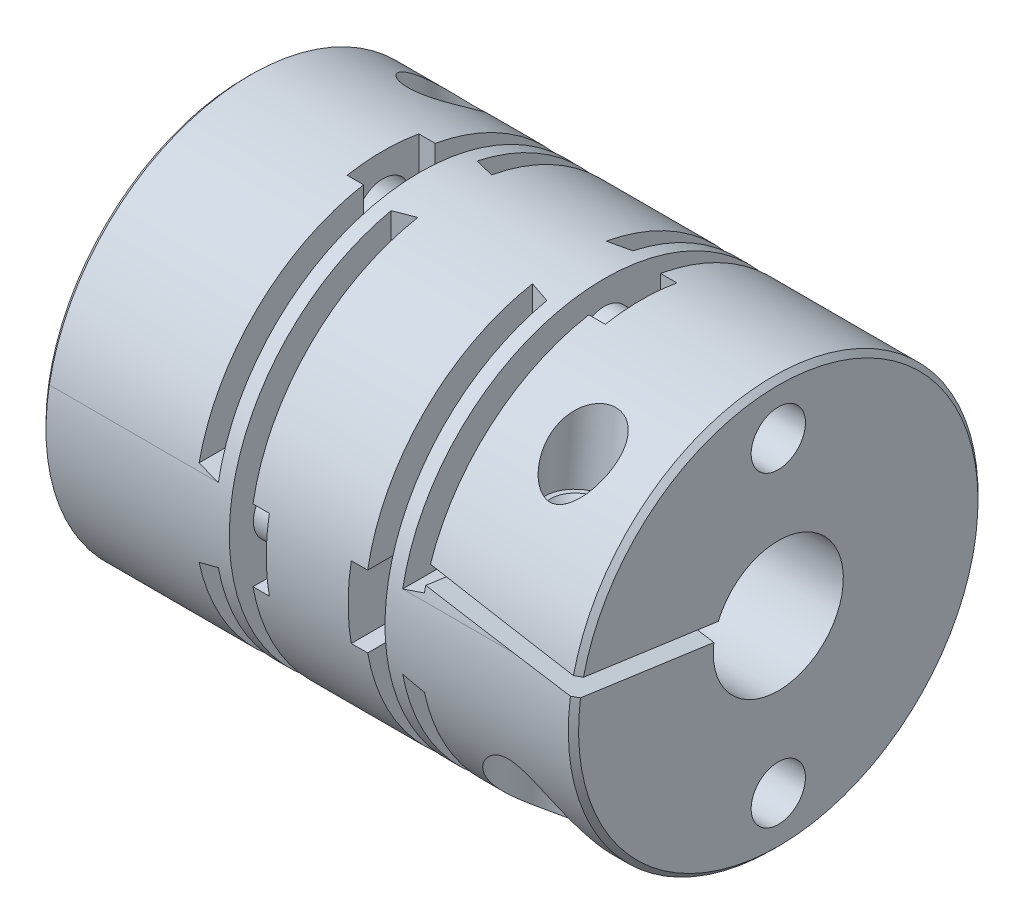
from build123d import *

# Parameters (mm, degrees)
CUT_EXTRUDE1_DEPTH      = 10
CUT_EXTRUDE2_DEPTH      = 10
CUT_EXTRUDE3_DEPTH      = 10
CUT_EXTRUDE3_DEPTH_BACK = 10
CUT_EXTRUDE4_DEPTH      = 10
CUT_EXTRUDE4_DEPTH_BACK = 10
CUT_EXTRUDE5_DEPTH      = 10
CUT_EXTRUDE5_DEPTH_BACK = 10
CUT_EXTRUDE6_DEPTH      = 10
CUT_EXTRUDE6_DEPTH_BACK = 10
CUT_EXTRUDE7_DEPTH      = 0.8
CUT_EXTRUDE8_DEPTH      = 0.8
CUT_EXTRUDE9_START      = 0.8
CUT_EXTRUDE9_DEPTH      = 0.8
CUT_EXTRUDE10_START     = 0.8
CUT_EXTRUDE10_DEPTH     = 0.8
CUT_EXTRUDE11_DEPTH     = 0.8
CUT_EXTRUDE12_DEPTH     = 0.8
CUT_EXTRUDE13_START     = 0.8
CUT_EXTRUDE13_DEPTH     = 0.8
CUT_EXTRUDE14_START     = 0.8
CUT_EXTRUDE14_DEPTH     = 0.8
SKETCH18_R              = 1.325
BOSS_EXTRUDE1_DEPTH     = 0.8
SKETCH19_R              = 1.325
BOSS_EXTRUDE2_DEPTH     = 0.8
SKETCH20_R              = 1.325
BOSS_EXTRUDE3_DEPTH     = 0.8
SKETCH21_R              = 1.325
BOSS_EXTRUDE4_DEPTH     = 0.8
BOSS_EXTRUDE5_START     = -0.8
SKETCH22_R              = 1.325
BOSS_EXTRUDE5_DEPTH     = 0.8
BOSS_EXTRUDE6_START     = -0.8
SKETCH23_R              = 1.325
BOSS_EXTRUDE6_DEPTH     = 0.8
BOSS_EXTRUDE7_START     = 0.8
SKETCH24_R              = 1.325
BOSS_EXTRUDE7_DEPTH     = 0.8
BOSS_EXTRUDE8_START     = 0.8
SKETCH25_R              = 1.325
BOSS_EXTRUDE8_DEPTH     = 0.8
CUT_EXTRUDE15_START     = 7.5
SKETCH26_R              = 1.325
CUT_EXTRUDE15_DEPTH     = 7.5
CUT_EXTRUDE16_START     = 7.5
SKETCH27_R              = 1.325
CUT_EXTRUDE16_DEPTH     = 7.5
SKETCH28_R              = 1.325
CUT_EXTRUDE17_DEPTH     = 7.5
SKETCH29_R              = 1.325
CUT_EXTRUDE18_DEPTH     = 7.5


with BuildPart() as part:
    # Sketch1 → Revolve1 (revolve)
    with BuildSketch(Plane.XY):
        Polygon((0, 3.175), (7.5, 3.175), (7.5, 4.05), (18.5, 4.05), (18.5, 3.175), (26, 3.175), (26, 9.75), (25.75, 10), (0.25, 10), (0, 9.75), align=None)
    revolve(axis=Axis((26, 0, 0), (-1, 0, 0)))

    # Sketch2 → Cut-Extrude1 (cut)
    with BuildSketch(Plane(origin=(0, 0, 0), x_dir=(1, 0, 0), z_dir=(0, -0.13917310096007, 0.9902680687415697))):
        Polygon((-1.351352679, 1.435577403), (-1.240014198, 0.643362948), (8.5, 2.012232674), (8.5, 2.820094732), align=None)
    extrude(amount=-CUT_EXTRUDE1_DEPTH, mode=Mode.SUBTRACT)

    # Sketch3 → Cut-Extrude2 (cut)
    with BuildSketch(Plane(origin=(0, 0, 0), x_dir=(1, 0, 0), z_dir=(0, 0.13917310096007, 0.9902680687415697))):
        Polygon((17.5, 1.14924509), (26, 0), (26.107188948, 0.79278656), (17.5, 1.956524164), align=None)
    extrude(amount=CUT_EXTRUDE2_DEPTH, mode=Mode.SUBTRACT)

    # Sketch4 → Cut-Revolve1 (revolve, cut)
    with BuildSketch(Plane(origin=(3.7, 0, 0), x_dir=(0, 0, -1), z_dir=(1, 0, 0))):
        Polygon((5.60370811, 10.528459309), (7.098000157, 10.659192923), (7.533778871, 5.678219432), (7.284730196, 5.656430497), (7.063379211, 5.392634664), (7.456713078, 0.896807992), (7.72050891, 0.675457006), (7.981976138, -2.313127088), (9.401553583, -2.188930155), (10.011643782, -9.162293041), (7.346822965, -9.395434653), align=None)
    revolve(axis=Axis((3.7, -9.395434653, -7.346822965), (0, 0.9961946980917458, 0.08715574274765596)), mode=Mode.SUBTRACT)

    # Sketch5 → Cut-Revolve2 (revolve, cut)
    with BuildSketch(Plane(origin=(22.3, 0, 0), x_dir=(0, 0, -1), z_dir=(1, 0, 0))):
        Polygon((-5.60370811, 10.528459309), (-4.109416063, 10.397725695), (-4.545194777, 5.416752204), (-4.794243451, 5.43854114), (-5.058039284, 5.217190154), (-5.381648556, 1.51831924), (-5.160297571, 1.254523408), (-5.491489393, -2.531016445), (-4.071911948, -2.655213378), (-4.682002148, -9.628576265), (-7.346822965, -9.395434653), align=None)
    revolve(axis=Axis((22.3, -9.395434653, 7.346822965), (0, 0.9961946980917458, -0.08715574274765596)), mode=Mode.SUBTRACT)

    # Sketch6 → Cut-Extrude3 (cut, two sides: drawn at the far end of the back side and taken through both)
    with BuildSketch(Plane.XY.offset(-CUT_EXTRUDE3_DEPTH_BACK)):
        Polygon((7.5, 10.5), (7.5, 2.1), (8.5, 1.8), (8.5, 10), (17.5, 10), (17.5, 1.8), (18.5, 2.1), (18.5, 10.5), align=None)
    extrude(amount=CUT_EXTRUDE3_DEPTH + CUT_EXTRUDE3_DEPTH_BACK, mode=Mode.SUBTRACT)

    # Sketch7 → Cut-Extrude4 (cut, two sides: drawn at the far end of the back side and taken through both)
    with BuildSketch(Plane.XY.offset(-CUT_EXTRUDE4_DEPTH_BACK)):
        Polygon((7.5, -10.5), (18.5, -10.5), (18.5, -2.1), (17.5, -1.8), (17.5, -10), (8.5, -10), (8.5, -1.8), (7.5, -2.1), align=None)
    extrude(amount=CUT_EXTRUDE4_DEPTH + CUT_EXTRUDE4_DEPTH_BACK, mode=Mode.SUBTRACT)

    # Sketch8 → Cut-Extrude5 (cut, two sides: drawn at the far end of the back side and taken through both)
    with BuildSketch(Plane(origin=(0, 0, 0), x_dir=(-1, 0, 0), z_dir=(0, 1, 0)).offset(-CUT_EXTRUDE5_DEPTH_BACK)):
        Polygon((-9.2, -10.5), (-9.2, -2.1), (-10.2, -1.8), (-10.2, -10), (-15.8, -10), (-15.8, -1.8), (-16.8, -2.1), (-16.8, -10.5), align=None)
    extrude(amount=CUT_EXTRUDE5_DEPTH + CUT_EXTRUDE5_DEPTH_BACK, mode=Mode.SUBTRACT)

    # Sketch9 → Cut-Extrude6 (cut, two sides: drawn at the far end of the back side and taken through both)
    with BuildSketch(Plane(origin=(0, 0, 0), x_dir=(-1, 0, 0), z_dir=(0, 1, 0)).offset(-CUT_EXTRUDE6_DEPTH_BACK)):
        Polygon((-9.2, 10.5), (-16.8, 10.5), (-16.8, 2.1), (-15.8, 1.8), (-15.8, 10), (-10.2, 10), (-10.2, 1.8), (-9.2, 2.1), align=None)
    extrude(amount=CUT_EXTRUDE6_DEPTH + CUT_EXTRUDE6_DEPTH_BACK, mode=Mode.SUBTRACT)

    # Sketch10 → Cut-Extrude7 (cut)
    with BuildSketch(Plane(origin=(15.8, 0, 0), x_dir=(0, 0, -1), z_dir=(1, 0, 0))):
        with BuildLine():
            Line((-10, -1.75), (-7.5, -1.75))
            ThreePointArc((-7.5, -1.75), (-5.75, 0), (-7.5, 1.75))
            Line((-7.5, 1.75), (-10, 1.75))
            Line((-10, 1.75), (-10, -1.75))
        make_face()
    extrude(amount=-CUT_EXTRUDE7_DEPTH, mode=Mode.SUBTRACT)

    # Sketch11 → Cut-Extrude8 (cut)
    with BuildSketch(Plane(origin=(15.8, 0, 0), x_dir=(0, 0, -1), z_dir=(1, 0, 0))):
        with BuildLine():
            Line((7.5, -1.75), (10, -1.75))
            Line((10, -1.75), (10, 1.75))
            Line((10, 1.75), (7.5, 1.75))
            ThreePointArc((7.5, 1.75), (5.75, 0), (7.5, -1.75))
        make_face()
    extrude(amount=-CUT_EXTRUDE8_DEPTH, mode=Mode.SUBTRACT)

    # Sketch12 → Cut-Extrude9 (cut)
    with BuildSketch(Plane(origin=(10.2, 0, 0), x_dir=(0, 0, -1), z_dir=(1, 0, 0)).offset(CUT_EXTRUDE9_START)):
        with BuildLine():
            Line((-10, -1.75), (-7.5, -1.75))
            ThreePointArc((-7.5, -1.75), (-5.75, 0), (-7.5, 1.75))
            Line((-7.5, 1.75), (-10, 1.75))
            Line((-10, 1.75), (-10, -1.75))
        make_face()
    extrude(amount=-CUT_EXTRUDE9_DEPTH, mode=Mode.SUBTRACT)

    # Sketch13 → Cut-Extrude10 (cut)
    with BuildSketch(Plane(origin=(10.2, 0, 0), x_dir=(0, 0, -1), z_dir=(1, 0, 0)).offset(CUT_EXTRUDE10_START)):
        with BuildLine():
            Line((7.5, -1.75), (10, -1.75))
            Line((10, -1.75), (10, 1.75))
            Line((10, 1.75), (7.5, 1.75))
            ThreePointArc((7.5, 1.75), (5.75, 0), (7.5, -1.75))
        make_face()
    extrude(amount=-CUT_EXTRUDE10_DEPTH, mode=Mode.SUBTRACT)

    # Sketch14 → Cut-Extrude11 (cut)
    with BuildSketch(Plane(origin=(7.5, 0, 0), x_dir=(0, 0, -1), z_dir=(1, 0, 0))):
        with BuildLine():
            Line((1.75, 7.5), (1.75, 10))
            Line((1.75, 10), (-1.75, 10))
            Line((-1.75, 10), (-1.75, 7.5))
            ThreePointArc((-1.75, 7.5), (0, 5.75), (1.75, 7.5))
        make_face()
    extrude(amount=-CUT_EXTRUDE11_DEPTH, mode=Mode.SUBTRACT)

    # Sketch15 → Cut-Extrude12 (cut)
    with BuildSketch(Plane(origin=(7.5, 0, 0), x_dir=(0, 0, -1), z_dir=(1, 0, 0))):
        with BuildLine():
            Line((-1.75, -7.5), (-1.75, -10))
            Line((-1.75, -10), (1.75, -10))
            Line((1.75, -10), (1.75, -7.5))
            ThreePointArc((1.75, -7.5), (0, -5.75), (-1.75, -7.5))
        make_face()
    extrude(amount=-CUT_EXTRUDE12_DEPTH, mode=Mode.SUBTRACT)

    # Sketch16 → Cut-Extrude13 (cut)
    with BuildSketch(Plane(origin=(18.5, 0, 0), x_dir=(0, 0, -1), z_dir=(1, 0, 0)).offset(CUT_EXTRUDE13_START)):
        with BuildLine():
            Line((1.75, 7.5), (1.75, 10))
            Line((1.75, 10), (-1.75, 10))
            Line((-1.75, 10), (-1.75, 7.5))
            ThreePointArc((-1.75, 7.5), (0, 5.75), (1.75, 7.5))
        make_face()
    extrude(amount=-CUT_EXTRUDE13_DEPTH, mode=Mode.SUBTRACT)

    # Sketch17 → Cut-Extrude14 (cut)
    with BuildSketch(Plane(origin=(18.5, 0, 0), x_dir=(0, 0, -1), z_dir=(1, 0, 0)).offset(CUT_EXTRUDE14_START)):
        with BuildLine():
            Line((-1.75, -7.5), (-1.75, -10))
            Line((-1.75, -10), (1.75, -10))
            Line((1.75, -10), (1.75, -7.5))
            ThreePointArc((1.75, -7.5), (0, -5.75), (-1.75, -7.5))
        make_face()
    extrude(amount=-CUT_EXTRUDE14_DEPTH, mode=Mode.SUBTRACT)

    # Sketch18 → Boss-Extrude1 (add)
    with BuildSketch(Plane(origin=(9.2, 0, 0), x_dir=(0, 0, -1), z_dir=(1, 0, 0))):
        with Locations((-7.5, 0)):
            Circle(SKETCH18_R)
    extrude(amount=BOSS_EXTRUDE1_DEPTH)

    # Sketch19 → Boss-Extrude2 (add)
    with BuildSketch(Plane(origin=(9.2, 0, 0), x_dir=(0, 0, -1), z_dir=(1, 0, 0))):
        with Locations((7.5, 0)):
            Circle(SKETCH19_R)
    extrude(amount=BOSS_EXTRUDE2_DEPTH)

    # Sketch20 → Boss-Extrude3 (add)
    with BuildSketch(Plane(origin=(8.5, 0, 0), x_dir=(0, 0, -1), z_dir=(1, 0, 0))):
        with Locations((0, 7.5)):
            Circle(SKETCH20_R)
    extrude(amount=-BOSS_EXTRUDE3_DEPTH)

    # Sketch21 → Boss-Extrude4 (add)
    with BuildSketch(Plane(origin=(8.5, 0, 0), x_dir=(0, 0, -1), z_dir=(1, 0, 0))):
        with Locations((0, -7.5)):
            Circle(SKETCH21_R)
    extrude(amount=-BOSS_EXTRUDE4_DEPTH)

    # Sketch22 → Boss-Extrude5 (add)
    with BuildSketch(Plane(origin=(16.8, 0, 0), x_dir=(0, 0, -1), z_dir=(1, 0, 0)).offset(BOSS_EXTRUDE5_START)):
        with Locations((-7.5, 0)):
            Circle(SKETCH22_R)
    extrude(amount=BOSS_EXTRUDE5_DEPTH)

    # Sketch23 → Boss-Extrude6 (add)
    with BuildSketch(Plane(origin=(16.8, 0, 0), x_dir=(0, 0, -1), z_dir=(1, 0, 0)).offset(BOSS_EXTRUDE6_START)):
        with Locations((7.5, 0)):
            Circle(SKETCH23_R)
    extrude(amount=BOSS_EXTRUDE6_DEPTH)

    # Sketch24 → Boss-Extrude7 (add)
    with BuildSketch(Plane(origin=(17.5, 0, 0), x_dir=(0, 0, -1), z_dir=(1, 0, 0)).offset(BOSS_EXTRUDE7_START)):
        with Locations((0, 7.5)):
            Circle(SKETCH24_R)
    extrude(amount=-BOSS_EXTRUDE7_DEPTH)

    # Sketch25 → Boss-Extrude8 (add)
    with BuildSketch(Plane(origin=(17.5, 0, 0), x_dir=(0, 0, -1), z_dir=(1, 0, 0)).offset(BOSS_EXTRUDE8_START)):
        with Locations((0, -7.5)):
            Circle(SKETCH25_R)
    extrude(amount=-BOSS_EXTRUDE8_DEPTH)

    # Sketch26 → Cut-Extrude15 (cut)
    with BuildSketch(Plane(origin=(0, 0, 0), x_dir=(0, 0, -1), z_dir=(1, 0, 0)).offset(CUT_EXTRUDE15_START)):
        with Locations((0, 7.5)):
            Circle(SKETCH26_R)
    extrude(amount=-CUT_EXTRUDE15_DEPTH, mode=Mode.SUBTRACT)

    # Sketch27 → Cut-Extrude16 (cut)
    with BuildSketch(Plane(origin=(0, 0, 0), x_dir=(0, 0, -1), z_dir=(1, 0, 0)).offset(CUT_EXTRUDE16_START)):
        with Locations((0, -7.5)):
            Circle(SKETCH27_R)
    extrude(amount=-CUT_EXTRUDE16_DEPTH, mode=Mode.SUBTRACT)

    # Sketch28 → Cut-Extrude17 (cut)
    with BuildSketch(Plane(origin=(26, 0, 0), x_dir=(0, 0, -1), z_dir=(1, 0, 0))):
        with Locations((0, 7.5)):
            Circle(SKETCH28_R)
    extrude(amount=-CUT_EXTRUDE17_DEPTH, mode=Mode.SUBTRACT)

    # Sketch29 → Cut-Extrude18 (cut)
    with BuildSketch(Plane(origin=(26, 0, 0), x_dir=(0, 0, -1), z_dir=(1, 0, 0))):
        with Locations((0, -7.5)):
            Circle(SKETCH29_R)
    extrude(amount=-CUT_EXTRUDE18_DEPTH, mode=Mode.SUBTRACT)


solid = part.part
